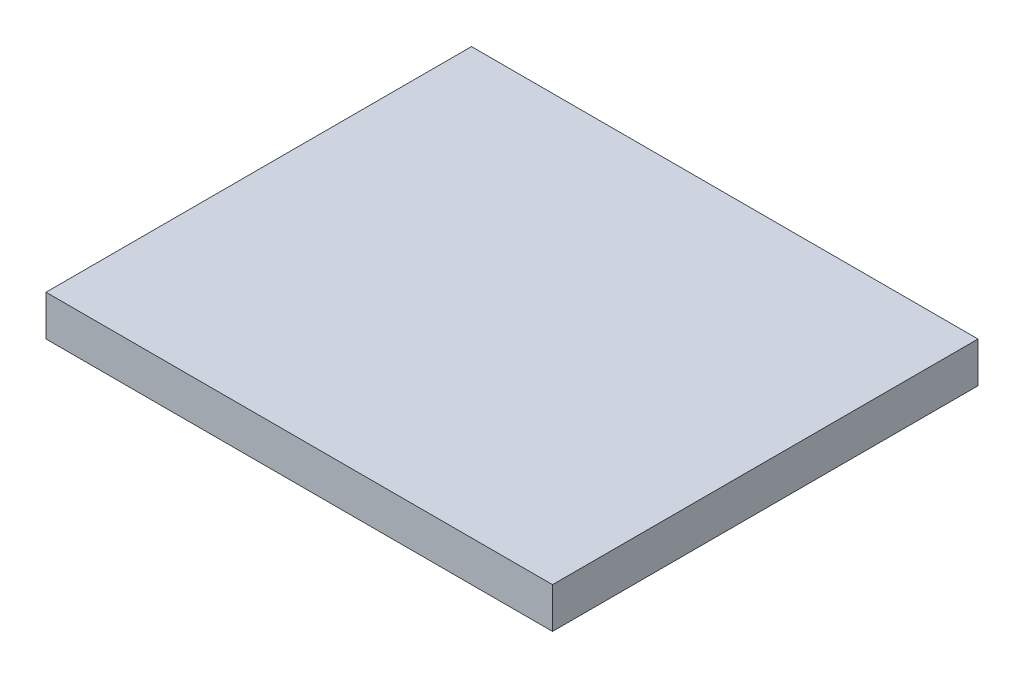
from build123d import *

# Parameters (mm, degrees)
SKETCH1_W           = 635
SKETCH1_H           = 533.4
BOSS_EXTRUDE1_DEPTH = 50.8


with BuildPart() as part:
    # Sketch1 → Boss-Extrude1 (new body)
    with BuildSketch(Plane(origin=(0, 0, 0), x_dir=(1, 0, 0), z_dir=(0, 1, 0))):
        with Locations((132.5, 83.3)):
            Rectangle(SKETCH1_W, SKETCH1_H)
    extrude(amount=BOSS_EXTRUDE1_DEPTH)


solid = part.part
